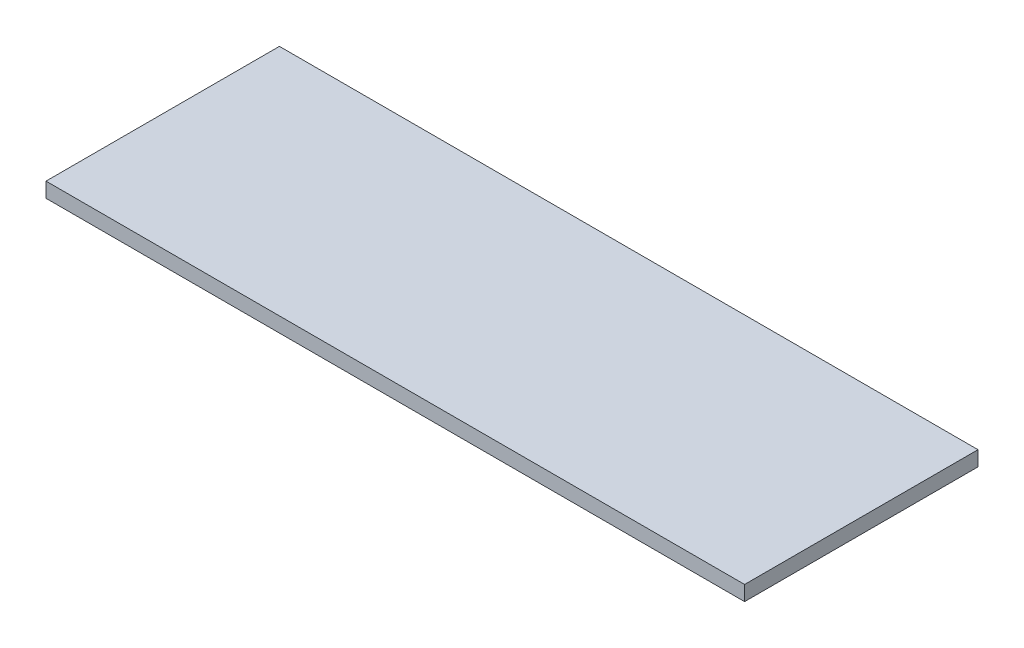
from build123d import *

# Parameters (mm, degrees)
SKETCH_1_W      = 844
SKETCH_1_H      = 282
EXTRUDE_1_DEPTH = 18


with BuildPart() as part:
    # Эскиз1 → Бобышка-Вытянуть1 (new body)
    with BuildSketch(Plane(origin=(0, 0, 0), x_dir=(1, 0, 0), z_dir=(0, 1, 0))):
        Rectangle(SKETCH_1_W, SKETCH_1_H)
    extrude(amount=EXTRUDE_1_DEPTH)


solid = part.part
